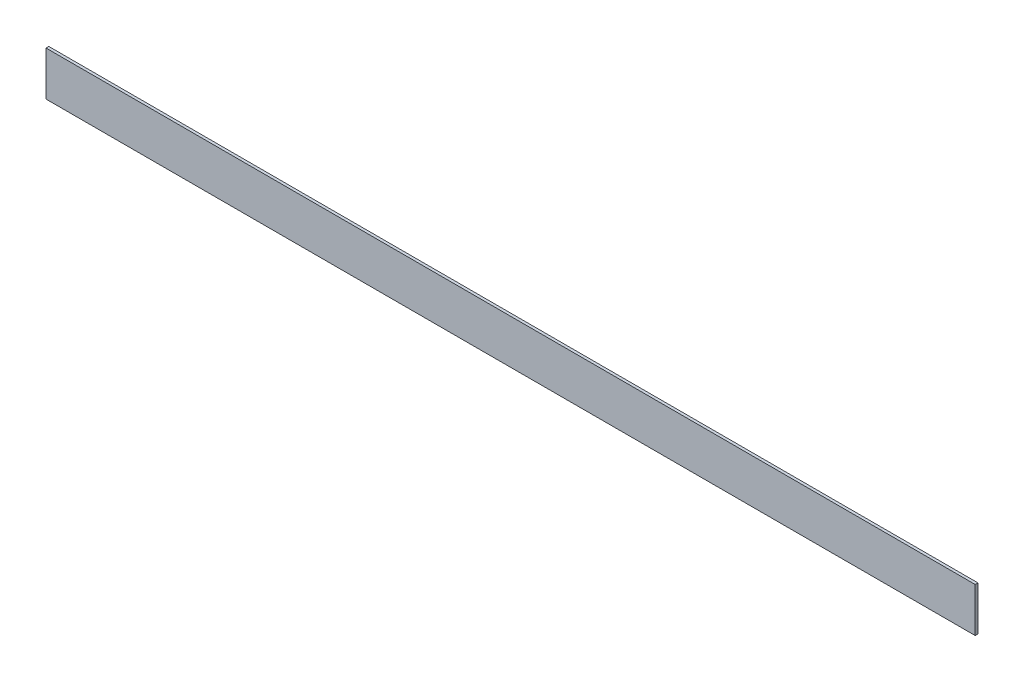
from build123d import *

# Parameters (mm, degrees)
SKETCH1_W           = 533.4
SKETCH1_H           = 25.4
BOSS_EXTRUDE1_DEPTH = 1.5875


with BuildPart() as part:
    # Sketch1 → Boss-Extrude1 (new body)
    with BuildSketch(Plane.XY):
        with Locations((137.836022729, 101.587432877)):
            Rectangle(SKETCH1_W, SKETCH1_H)
    extrude(amount=BOSS_EXTRUDE1_DEPTH)


solid = part.part
